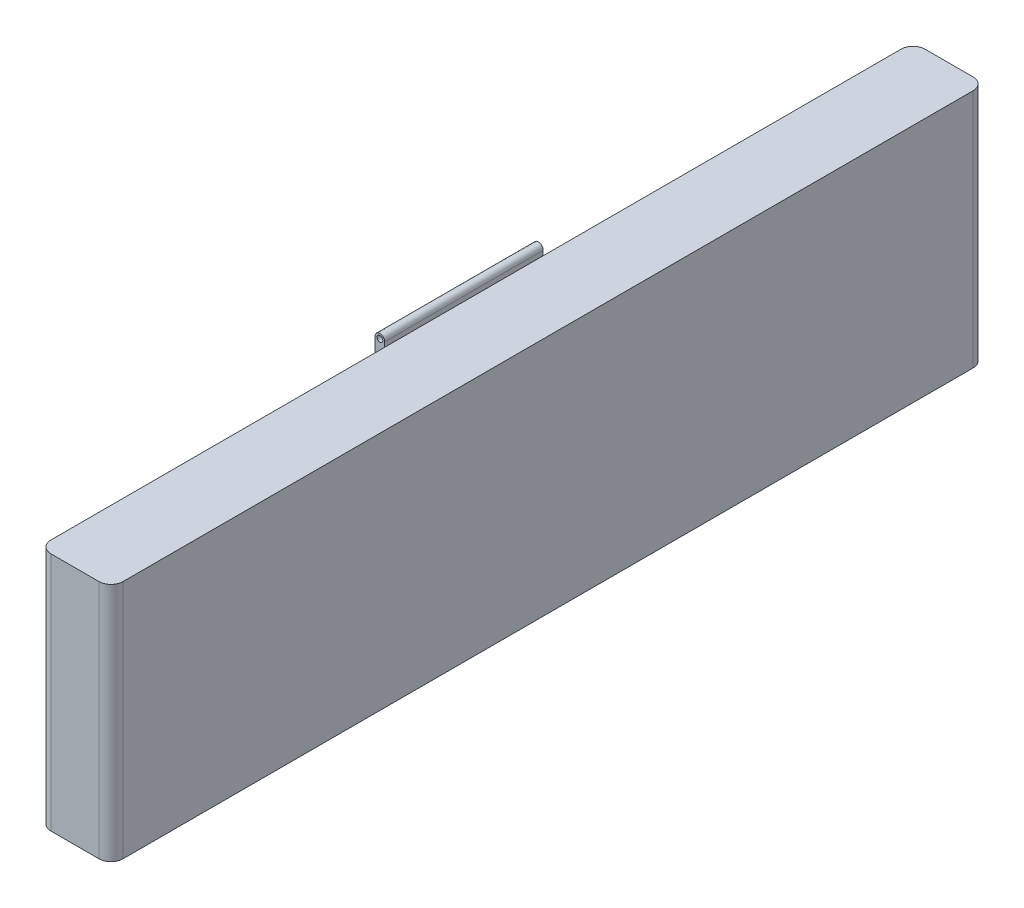
from build123d import *

# Parameters (mm, degrees)
SKETCH2_W           = 18.2
SKETCH2_H           = 5
BOSS_EXTRUDE1_DEPTH = 1.5
SKETCH4_W           = 3.6
SKETCH4_H           = 0.6
CUT_EXTRUDE1_DEPTH  = 0.6
SKETCH5_W           = 3.3
SKETCH5_H           = 0.5
BOSS_EXTRUDE2_DEPTH = 0.2
BOSS_EXTRUDE5_DEPTH = 3.3
SKETCH9_R           = 0.06
CUT_EXTRUDE5_DEPTH  = 12
FILLET1_R           = 0.25


with BuildPart() as part:
    # Sketch2 → Boss-Extrude1 (new body)
    with BuildSketch(Plane(origin=(0, 0, 0), x_dir=(0, 0, -1), z_dir=(1, 0, 0))):
        with Locations((-9.1, 2.5)):
            Rectangle(SKETCH2_W, SKETCH2_H)
    extrude(amount=BOSS_EXTRUDE1_DEPTH)

    # Sketch3 → Revolve1 (revolve)
    with BuildSketch(Plane.XY.offset(11)):
        Polygon((0, 2.5), (0, 3.1), (-0.3, 3.1), (-0.3, 2.8), (-0.6, 2.8), (-0.6, 2.5), align=None)
    revolve(axis=Axis((0, 2.5, 11), (-1, 0, 0)))

    # Sketch4 → Cut-Extrude1 (cut)
    with BuildSketch(Plane.ZY):
        with Locations((7.7, 2.5)):
            Rectangle(SKETCH4_W, SKETCH4_H)
    extrude(amount=-CUT_EXTRUDE1_DEPTH, mode=Mode.SUBTRACT)

    # Sketch5 → Boss-Extrude2 (add)
    with BuildSketch(Plane.ZY):
        with Locations((9.35, 4.85)):
            Rectangle(SKETCH5_W, SKETCH5_H)
    boss_extrude2 = extrude(amount=BOSS_EXTRUDE2_DEPTH)

    # Sketch6 → Boss-Extrude5 (add)
    with BuildSketch(Plane.XY.offset(11)):
        with BuildLine():
            Line((-0.2, 5.1), (0, 5.1))
            ThreePointArc((0, 5.1), (-0.1, 5.2), (-0.2, 5.1))
        make_face()
    boss_extrude5 = extrude(amount=-BOSS_EXTRUDE5_DEPTH)

    # Sketch9 → Cut-Extrude5 (cut, through all)
    with BuildSketch(Plane.XY.offset(11)):
        with Locations((-0.1, 5.1)):
            Circle(SKETCH9_R)
    cut_extrude5 = extrude(amount=-CUT_EXTRUDE5_DEPTH, mode=Mode.SUBTRACT)

    # Mirror8: Boss-Extrude2, Boss-Extrude5, Cut-Extrude5 across plane
    add(boss_extrude2.mirror(Plane.ZX.offset(2.5)))
    add(boss_extrude5.mirror(Plane.ZX.offset(2.5)))
    add(cut_extrude5.mirror(Plane.ZX.offset(2.5)), mode=Mode.SUBTRACT)

    # Fillet1
    fillet1_edges = [part.edges().sort_by_distance(p)[0] for p in [
        (1.5, 2.5, 18.2),
        (0, 2.5, 18.2),
        (0, 2.5, 0),
        (1.5, 2.5, 0),
    ]]
    fillet(fillet1_edges, radius=FILLET1_R)


solid = part.part
